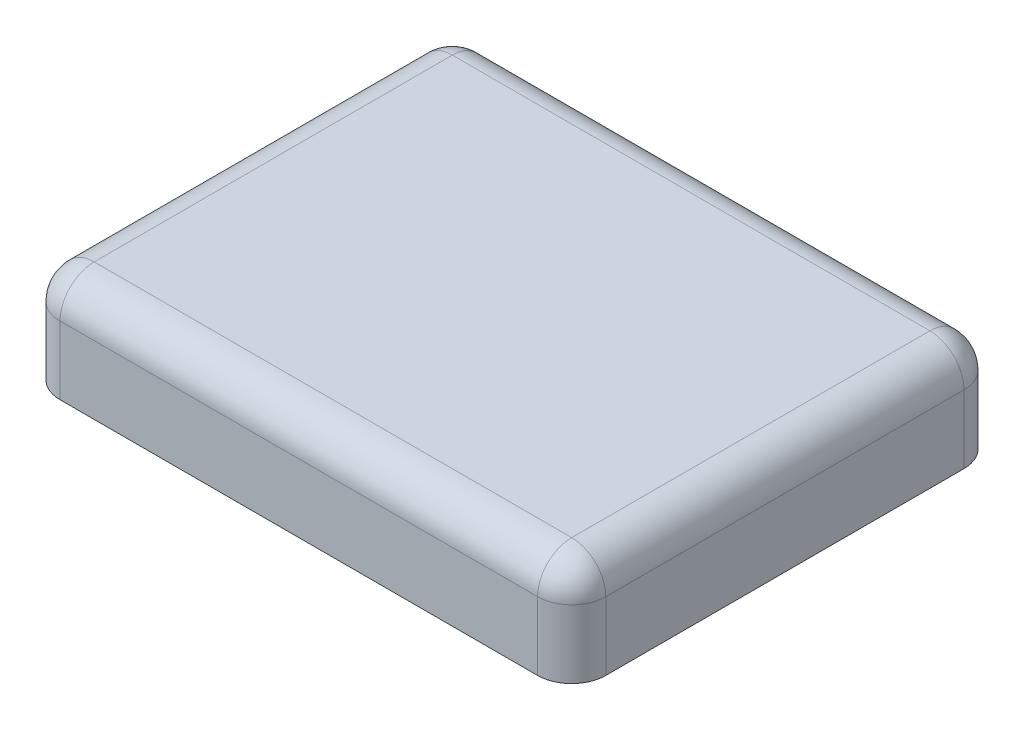
from build123d import *

# Parameters (mm, degrees)
BASES_W    = 3.2
BASES_H    = 2.5
BASE_DEPTH = 0.6
SIDEF_R    = 0.2
TOPF_R     = 0.2


with BuildPart() as part:
    # BaseS → Base (new body)
    with BuildSketch(Plane(origin=(0, 0, 0), x_dir=(1, 0, 0), z_dir=(0, 1, 0))):
        Rectangle(BASES_W, BASES_H)
    extrude(amount=BASE_DEPTH)

    # SideF
    sidef_edges = [part.edges().sort_by_distance(p)[0] for p in [
        (1.6, 0.3, 1.25),
        (-1.6, 0.3, 1.25),
        (-1.6, 0.3, -1.25),
        (1.6, 0.3, -1.25),
    ]]
    fillet(sidef_edges, radius=SIDEF_R)

    # TopF
    topf_edges = [part.edges().sort_by_distance(p)[0] for p in [
        (1.6, 0.6, 0),
        (0, 0.6, 1.25),
        (0, 0.6, -1.25),
        (-1.6, 0.6, 0),
        (-1.541421356, 0.6, -1.191421356),
        (-1.541421356, 0.6, 1.191421356),
        (1.541421356, 0.6, -1.191421356),
        (1.541421356, 0.6, 1.191421356),
    ]]
    fillet(topf_edges, radius=TOPF_R)


solid = part.part
